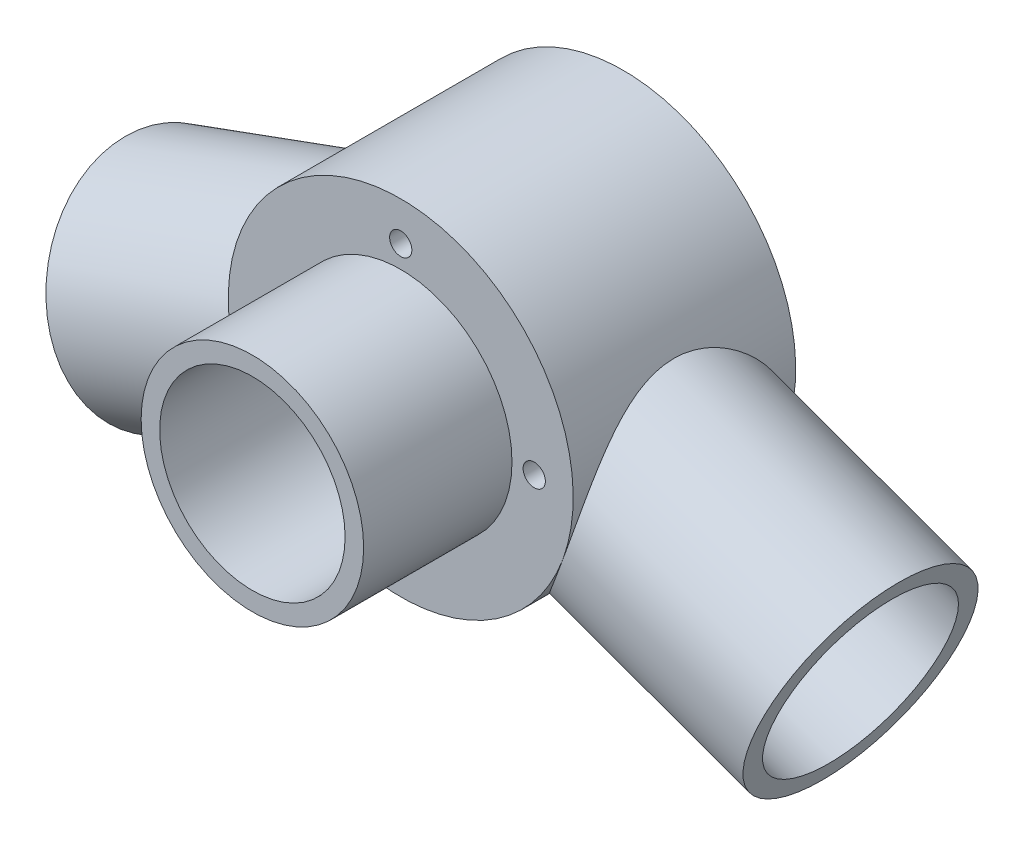
from build123d import *

# Parameters (mm, degrees)
CROQUIS1_R              = 15
CROQUIS1_R_2            = 12.5
SALIENTE_EXTRUIR1_DEPTH = 20
CROQUIS8_R              = 23.25
CROQUIS8_R_2            = 1.5
SALIENTE_EXTRUIR2_DEPTH = 30
SALIENTE_EXTRUIR4_REACH = 81.8
CROQUIS6_R              = 15
CROQUIS6_R_2            = 12.5
SALIENTE_EXTRUIR5_REACH = 108.924
CROQUIS7_R              = 15
CROQUIS7_R_2            = 12.5
CROQUIS9_R              = 12.5
CORTAR_EXTRUIR1_DEPTH   = 31.000000103


with BuildPart() as part:
    # Croquis1 → Saliente-Extruir1 (new body)
    with BuildSketch(Plane.XY):
        Circle(CROQUIS1_R)
        Circle(CROQUIS1_R_2, mode=Mode.SUBTRACT)
    extrude(amount=-SALIENTE_EXTRUIR1_DEPTH)

    # Croquis8 → Saliente-Extruir2 (add)
    with BuildSketch(Plane(origin=(0, 0, -20), x_dir=(-1, 0, 0), z_dir=(0, 0, -1))):
        Circle(CROQUIS8_R)
        with Locations((0, 18)):
            Circle(CROQUIS8_R_2, mode=Mode.SUBTRACT)
        with Locations((18, 0)):
            Circle(CROQUIS8_R_2, mode=Mode.SUBTRACT)
        with Locations((0, -18)):
            Circle(CROQUIS8_R_2, mode=Mode.SUBTRACT)
        with Locations((-18, 0)):
            Circle(CROQUIS8_R_2, mode=Mode.SUBTRACT)
    extrude(amount=SALIENTE_EXTRUIR2_DEPTH)

    # Croquis6 → Saliente-Extruir4 (add, up to next)
    with BuildSketch(Plane(origin=(46.984631039, -17.101007166, -35), x_dir=(0, 0, -1), z_dir=(0.939692621, -0.342020143, 0)), mode=Mode.PRIVATE) as saliente_extruir4_sk1:
        Circle(CROQUIS6_R)
        Circle(CROQUIS6_R_2, mode=Mode.SUBTRACT)
    saliente_extruir4_tool1 = extrude(saliente_extruir4_sk1.sketch, amount=-SALIENTE_EXTRUIR4_REACH, mode=Mode.PRIVATE) - part.part
    add(saliente_extruir4_tool1.solids().sort_by_distance((46.984631, -17.101007, -20.424264))[0])

    # Croquis7 → Saliente-Extruir5 (add, up to next)
    with BuildSketch(Plane(origin=(-46.984631039, -17.101007166, -35), x_dir=(0, 0, 1), z_dir=(-0.939692621, -0.342020143, 0)), mode=Mode.PRIVATE) as saliente_extruir5_sk1:
        Circle(CROQUIS7_R)
        Circle(CROQUIS7_R_2, mode=Mode.SUBTRACT)
    saliente_extruir5_tool1 = extrude(saliente_extruir5_sk1.sketch, amount=-SALIENTE_EXTRUIR5_REACH, mode=Mode.PRIVATE) - part.part
    add(saliente_extruir5_tool1.solids().sort_by_distance((-46.984631, -17.101007, -49.575736))[0])

    # Croquis9 → Cortar-Extruir1 (cut, through all)
    with BuildSketch(Plane.XY.offset(-20)):
        Circle(CROQUIS9_R)
    extrude(amount=-CORTAR_EXTRUIR1_DEPTH, mode=Mode.SUBTRACT)


solid = part.part
